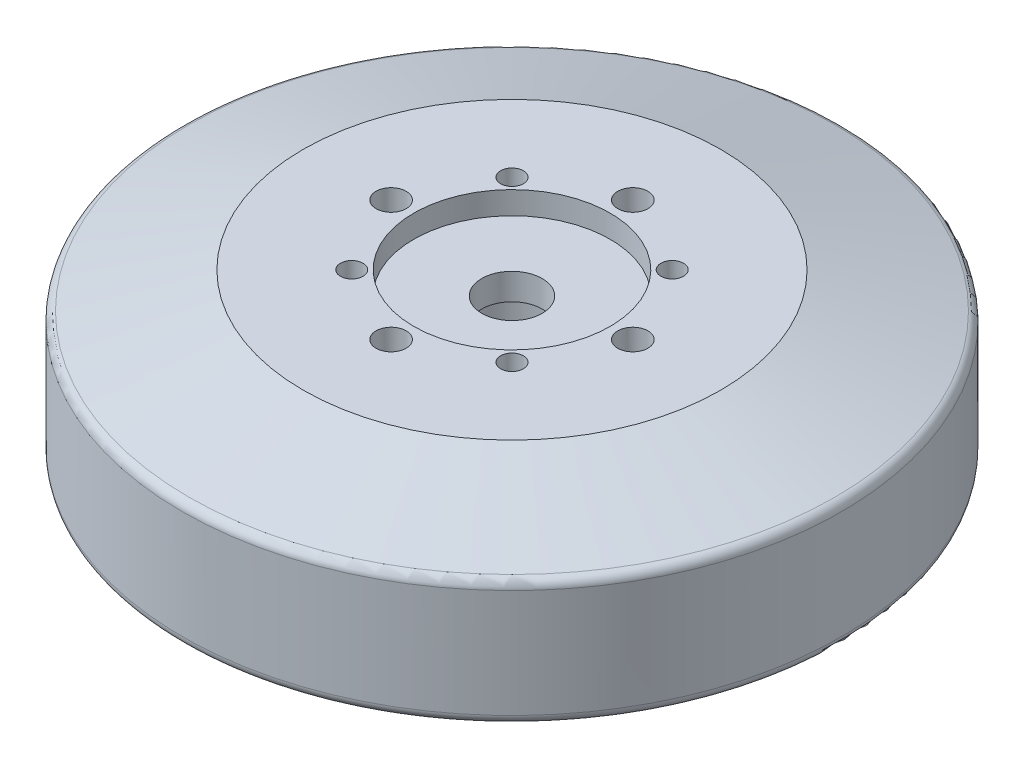
from build123d import *

# Parameters (mm, degrees)
SKETCH1_R           = 43.625
BOSS_EXTRUDE1_DEPTH = 26.5
CHAMFER1_SIZE       = 5
CHAMFER1_SIZE2      = 16
SKETCH2_R           = 2
SKETCH2_R_2         = 1.5
CUT_EXTRUDE1_DEPTH  = 6
SKETCH3_R           = 13
CUT_EXTRUDE2_DEPTH  = 3
CHAMFER2_SIZE       = 23
CHAMFER2_SIZE2      = 5.23
FILLET1_R           = 1.27
SKETCH5_R           = 4
CUT_EXTRUDE3_DEPTH  = 68.145598343
SKETCH4_R           = 6.35
CUT_EXTRUDE4_DEPTH  = 20
SKETCH6_R           = 1.5
CUT_EXTRUDE5_DEPTH  = 6
CIRPATTERN1_COUNT   = 4


with BuildPart() as part:
    # Sketch1 → Boss-Extrude1 (new body)
    with BuildSketch(Plane(origin=(0, 0, 0), x_dir=(1, 0, 0), z_dir=(0, 1, 0))):
        Circle(SKETCH1_R)
    extrude(amount=BOSS_EXTRUDE1_DEPTH)

    # Chamfer1
    chamfer1_edges = [part.edges().sort_by_distance(p)[0] for p in [
        (-43.625, 26.5, 0),
    ]]
    chamfer1_side = [part.faces().sort_by_distance(p)[0] for p in [
        (-43.625, 13.25, 0),
    ]]
    chamfer(chamfer1_edges, length=CHAMFER1_SIZE, length2=CHAMFER1_SIZE2, reference=chamfer1_side[0])

    # Sketch2 → Cut-Extrude1 (cut)
    with BuildSketch(Plane(origin=(0, 26.5, 0), x_dir=(1, 0, 0), z_dir=(0, 1, 0))):
        with Locations((16, 0)):
            Circle(SKETCH2_R)
        with Locations((10.606601718, 10.606601718)):
            Circle(SKETCH2_R_2)
    cut_extrude1 = extrude(amount=-CUT_EXTRUDE1_DEPTH, mode=Mode.SUBTRACT)

    # Sketch3 → Cut-Extrude2 (cut)
    with BuildSketch(Plane(origin=(0, 26.5, 0), x_dir=(1, 0, 0), z_dir=(0, 1, 0))):
        Circle(SKETCH3_R)
    extrude(amount=-CUT_EXTRUDE2_DEPTH, mode=Mode.SUBTRACT)

    # Chamfer2
    chamfer2_edges = [part.edges().sort_by_distance(p)[0] for p in [
        (-43.625, 0, 0),
    ]]
    chamfer2_side = [part.faces().sort_by_distance(p)[0] for p in [
        (0, 0, 0),
    ]]
    chamfer(chamfer2_edges, length=CHAMFER2_SIZE, length2=CHAMFER2_SIZE2, reference=chamfer2_side[0])

    # Fillet1
    fillet1_edges = [part.edges().sort_by_distance(p)[0] for p in [
        (-43.625, 5.23, 0),
        (-43.625, 21.5, 0),
    ]]
    fillet(fillet1_edges, radius=FILLET1_R)

    # Sketch5 → Cut-Extrude3 (cut, through all)
    with BuildSketch(Plane(origin=(0, 26.5, 0), x_dir=(1, 0, 0), z_dir=(0, 1, 0))):
        Circle(SKETCH5_R)
    extrude(amount=-CUT_EXTRUDE3_DEPTH, mode=Mode.SUBTRACT)

    # Sketch4 → Cut-Extrude4 (cut)
    with BuildSketch(Plane.XZ):
        Circle(SKETCH4_R)
    extrude(amount=-CUT_EXTRUDE4_DEPTH, mode=Mode.SUBTRACT)

    # Sketch6 → Cut-Extrude5 (cut)
    with BuildSketch(Plane.XZ):
        with Locations((0, 17.5)):
            Circle(SKETCH6_R)
        with Locations((0, 12.5)):
            Circle(SKETCH6_R)
        with Locations((-12.374368671, 12.374368671)):
            Circle(SKETCH6_R)
    cut_extrude5 = extrude(amount=-CUT_EXTRUDE5_DEPTH, mode=Mode.SUBTRACT)

    # CirPattern1: Cut-Extrude1, Cut-Extrude5 ×4 about axis
    cirpattern1_axis = Axis((0, 23.5, 0), (0, 1, 0))
    add([cut_extrude1.rotate(cirpattern1_axis, i * 360 / CIRPATTERN1_COUNT) for i in range(1, CIRPATTERN1_COUNT)], mode=Mode.SUBTRACT)
    add([cut_extrude5.rotate(cirpattern1_axis, i * 360 / CIRPATTERN1_COUNT) for i in range(1, CIRPATTERN1_COUNT)], mode=Mode.SUBTRACT)


solid = part.part
